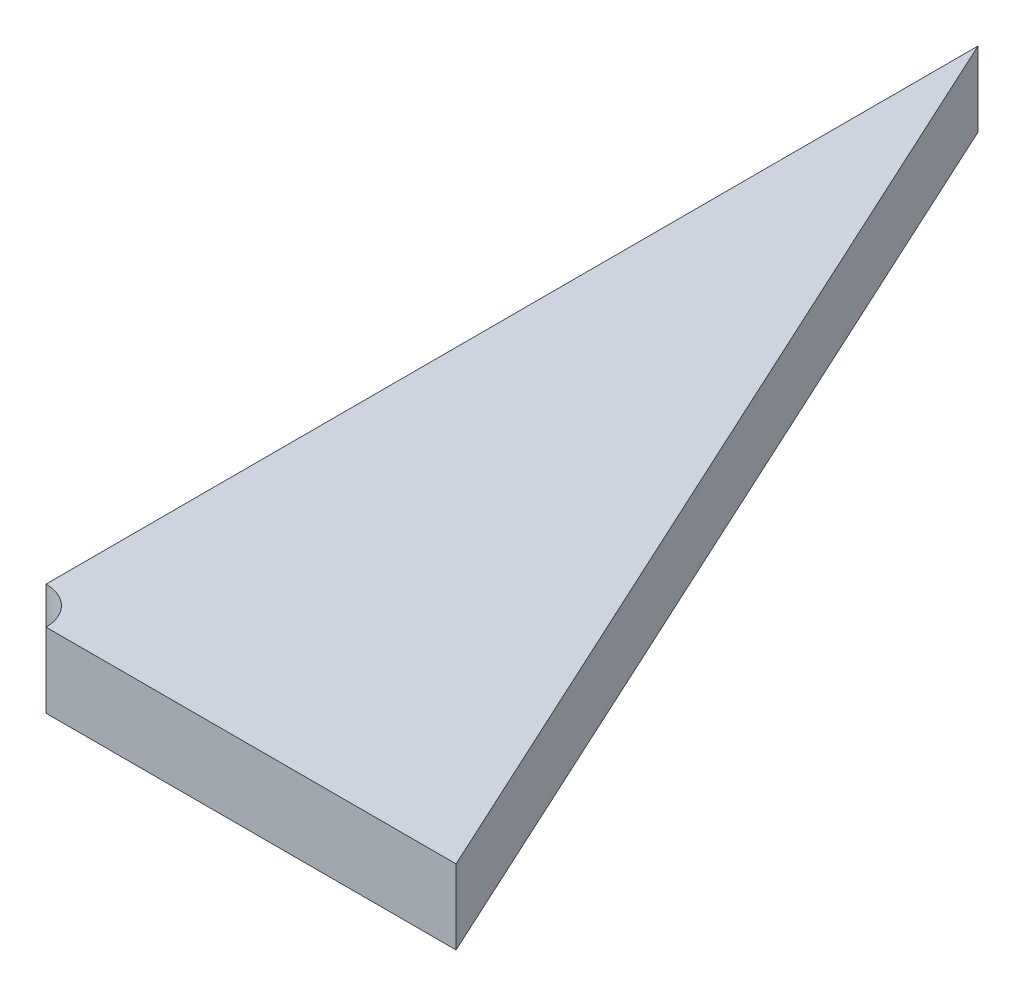
from build123d import *

# Parameters (mm, degrees)
BOSS_EXTRUDE1_DEPTH = 6.35
CUT_EXTRUDE1_REACH  = 14.7
SKETCH3_R           = 6.35


with BuildPart() as part:
    # Sketch2 → Boss-Extrude1 (new body, symmetric)
    with BuildSketch(Plane(origin=(0, 0, 0), x_dir=(1, 0, 0), z_dir=(0, 1, 0))):
        Polygon((0, 0), (76.2, 0), (0, 165.1), align=None)
    extrude(amount=BOSS_EXTRUDE1_DEPTH, both=True)

    # Sketch3 → Cut-Extrude1 (cut, up to next)
    with BuildSketch(Plane(origin=(0, 6.35, 0), x_dir=(1, 0, 0), z_dir=(0, 1, 0)), mode=Mode.PRIVATE) as cut_extrude1_sk1:
        Circle(SKETCH3_R)
    cut_extrude1_tool1 = extrude(cut_extrude1_sk1.sketch, amount=-CUT_EXTRUDE1_REACH, mode=Mode.PRIVATE) & part.part
    add(cut_extrude1_tool1.solids().sort_by_distance((0, 6.35, 0))[0], mode=Mode.SUBTRACT)


solid = part.part
